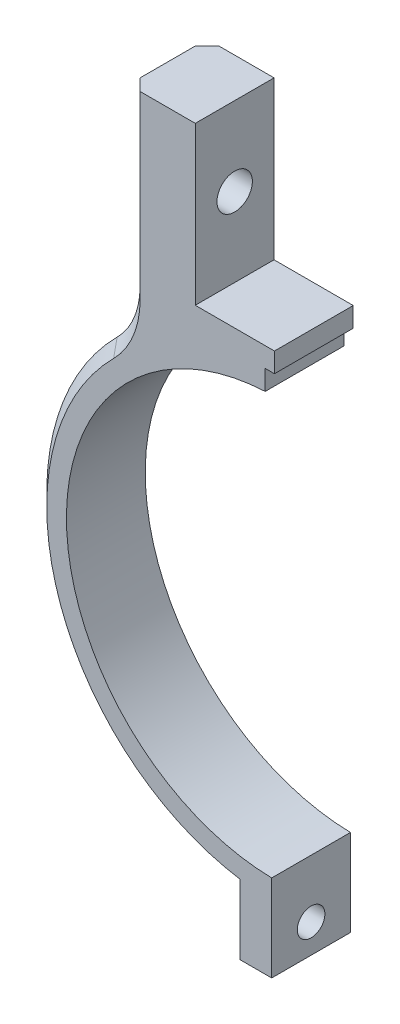
from build123d import *

# Parameters (mm, degrees)
AUFSATZ_LINEAR_AUSTRAGEN1_DEPTH = 10
SKIZZE2_R                       = 1.75
SCHNITT_LINEAR_AUSTRAGEN1_DEPTH = 36.05
SKIZZE4_R                       = 2.25
SCHNITT_LINEAR_AUSTRAGEN3_DEPTH = 50.25
VERRUNDUNG1_R                   = 10
SCHNITT_LINEAR_AUSTRAGEN5_DEPTH = 11
FASE1_SIZE                      = 1.5
SCHNITT_LINEAR_AUSTRAGEN6_DEPTH = 11


with BuildPart() as part:
    # Skizze1 → Aufsatz-Linear austragen1 (new body)
    with BuildSketch(Plane.XY):
        with BuildLine():
            Line((0.5, -26.545291485), (0.5, -30.545908073))
            Line((0.5, -30.545908073), (0.5, -37.545908073))
            Line((0.5, -37.545908073), (4.5, -37.545908073))
            Line((4.5, -37.545908073), (4.5, -30.216758595))
            ThreePointArc((4.5, -30.216758595), (29.558680329, -7.719256261), (18.7, 24.158073185))
            Line((18.7, 24.158073185), (18.7, 51.55))
            Line((18.7, 51.55), (10.2, 51.55))
            Line((10.2, 51.55), (10.2, 31.55))
            Line((10.2, 31.55), (-10.2, 31.55))
            Line((-10.2, 31.55), (-10.2, 51.55))
            Line((-10.2, 51.55), (-18.7, 51.55))
            Line((-18.7, 51.55), (-18.7, 24.158073185))
            ThreePointArc((-18.7, 24.158073185), (-29.558680329, -7.719256261), (-4.5, -30.216758595))
            Line((-4.5, -30.216758595), (-4.5, -37.545908073))
            Line((-4.5, -37.545908073), (-0.5, -37.545908073))
            Line((-0.5, -37.545908073), (-0.5, -30.545908073))
            Line((-0.5, -30.545908073), (-0.5, -26.545291485))
            ThreePointArc((-0.5, -26.545291485), (0, 26.55), (0.5, -26.545291485))
        make_face()
    extrude(amount=AUFSATZ_LINEAR_AUSTRAGEN1_DEPTH)

    # Skizze2 → Schnitt-Linear austragen1 (cut, through all)
    with BuildSketch(Plane.ZY.offset(4.5)):
        with Locations((5, -33.881333334)):
            Circle(SKIZZE2_R)
    extrude(amount=-SCHNITT_LINEAR_AUSTRAGEN1_DEPTH, mode=Mode.SUBTRACT)

    # Skizze4 → Schnitt-Linear austragen3 (cut, through all)
    with BuildSketch(Plane.ZY.offset(18.7)):
        with Locations((5, 41.55)):
            Circle(SKIZZE4_R)
    extrude(amount=-SCHNITT_LINEAR_AUSTRAGEN3_DEPTH, mode=Mode.SUBTRACT)

    # Verrundung1
    verrundung1_edges = [part.edges().sort_by_distance(p)[0] for p in [
        (-18.7, 24.158073185, 5),
        (18.7, 24.158073185, 5),
    ]]
    fillet(verrundung1_edges, radius=VERRUNDUNG1_R)

    # Skizze6 → Schnitt-Linear austragen5 (cut, through all)
    with BuildSketch(Plane.XY):
        Polygon((0, 0), (0, 63.91348789), (40.013946788, 63.91348789), (48.360414216, -54.819102682), (0, -54.819102682), align=None)
    extrude(amount=SCHNITT_LINEAR_AUSTRAGEN5_DEPTH, mode=Mode.SUBTRACT)

    # Fase1
    fase1_edges = [part.edges().sort_by_distance(p)[0] for p in [
        (-18.7, 40.098167422, 0),
        (-18.7, 40.098167422, 10),
        (-29.006358008, -9.588206043, 0),
        (-29.006358008, -9.588206043, 10),
        (-19.459415096, 24.823823807, 0),
        (-19.459415096, 24.823823807, 10),
    ]]
    chamfer(fase1_edges, length=FASE1_SIZE)

    # Skizze7 → Schnitt-Linear austragen6 (cut, through all)
    with BuildSketch(Plane.XY.offset(10)):
        Polygon((1.325, 29.05), (0, 29.05), (0, 31.55), (-0.15, 31.55), (-0.15, 29.05), (-1.325, 29.05), (-1.325, 25.137104209), (1.325, 25.137104209), align=None)
    extrude(amount=-SCHNITT_LINEAR_AUSTRAGEN6_DEPTH, mode=Mode.SUBTRACT)


solid = part.part
